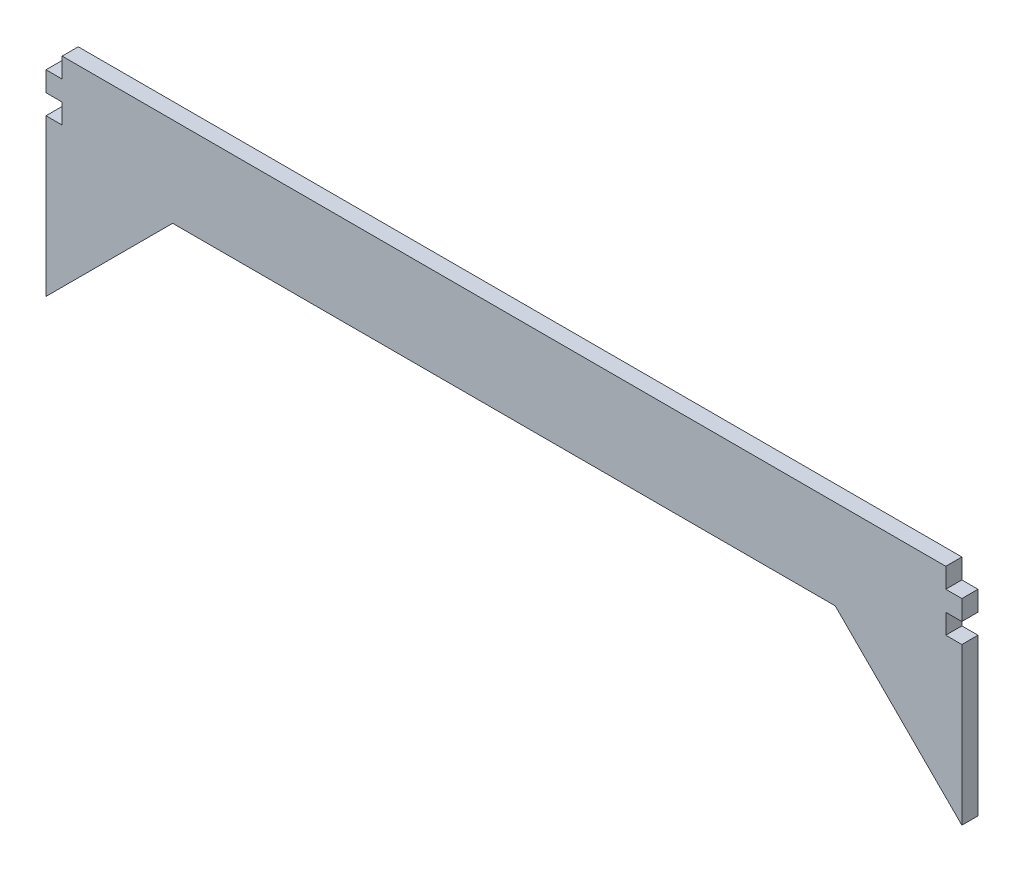
from build123d import *

# Parameters (mm, degrees)
BOSS_EXTRUDE1_DEPTH = 2.7


with BuildPart() as part:
    # Sketch1 → Boss-Extrude1 (new body)
    with BuildSketch(Plane.XY):
        Polygon((-76.7, -1.666666667), (-76.7, 1.666666667), (-74, 1.666666667), (-74, 5), (74, 5), (74, 1.666666667), (76.7, 1.666666667), (76.7, -1.666666667), (74, -1.666666667), (74, -5), (76.7, -5), (76.7, -10), (76.7, -31.213203436), (55.486796564, -10), (-55.486796564, -10), (-76.7, -31.213203436), (-76.7, -10), (-76.7, -5), (-74, -5), (-74, -1.666666667), align=None)
    extrude(amount=BOSS_EXTRUDE1_DEPTH)


solid = part.part
